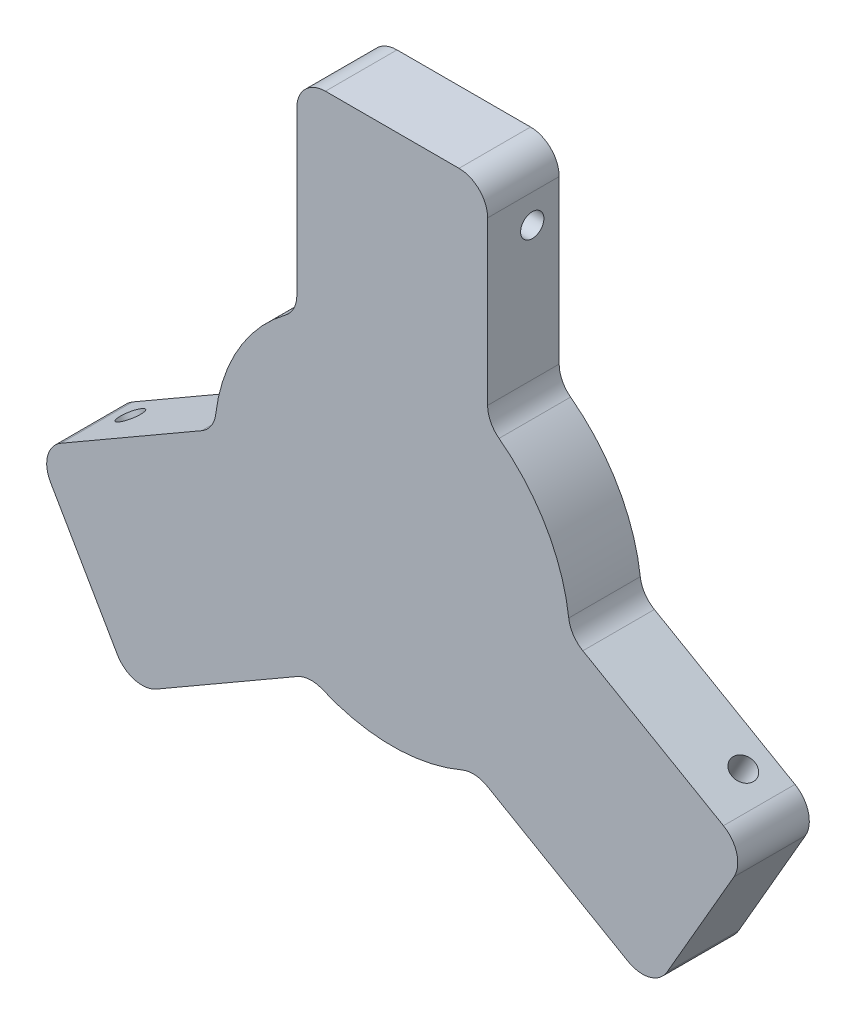
from build123d import *

# Parameters (mm, degrees)
BOSS_EXTRUDE1_DEPTH = 9.525
SKETCH3_R           = 1.55
CUT_EXTRUDE2_DEPTH  = 5.08
CUT_EXTRUDE3_START  = -5.08
SKETCH4_R           = 1.55
CUT_EXTRUDE3_DEPTH  = 5.08
CIRPATTERN2_COUNT   = 3


with BuildPart() as part:
    # Sketch1 → Boss-Extrude1 (new body)
    with BuildSketch(Plane.XY):
        with BuildLine():
            Line((12.7, 21.969079793), (12.7, 43.5864))
            ThreePointArc((12.7, 43.5864), (11.584076836, 46.280476836), (8.89, 47.3964))
            Line((8.89, 47.3964), (-8.89, 47.3964))
            ThreePointArc((-8.89, 47.3964), (-11.584076836, 46.280476836), (-12.7, 43.5864))
            Line((-12.7, 43.5864), (-12.7, 21.969079793))
            ThreePointArc((-12.7, 21.969079793), (-13.101409662, 20.266842468), (-14.221056121, 18.923289925))
            ThreePointArc((-14.221056121, 18.923289925), (-20.499926929, 11.835638331), (-23.498577859, 2.854150907))
            ThreePointArc((-23.498577859, 2.854150907), (-24.102305263, 1.212732359), (-25.375781199, 0.013982731))
            Line((-25.375781199, 0.013982731), (-44.09692966, -10.794677372))
            ThreePointArc((-44.09692966, -10.794677372), (-45.872107058, -13.108133599), (-45.491486448, -15.99923416))
            Line((-45.491486448, -15.99923416), (-36.601486448, -31.39716584))
            ThreePointArc((-36.601486448, -31.39716584), (-34.288030221, -33.172343238), (-31.39692966, -32.791722628))
            Line((-31.39692966, -32.791722628), (-12.675781199, -21.983062525))
            ThreePointArc((-12.675781199, -21.983062525), (-11.000895601, -21.479574827), (-9.277521738, -21.777440832))
            ThreePointArc((-9.277521738, -21.777440832), (0, -23.671276662), (9.277521738, -21.777440832))
            ThreePointArc((9.277521738, -21.777440832), (11.000895601, -21.479574827), (12.675781199, -21.983062525))
            Line((12.675781199, -21.983062525), (31.39692966, -32.791722628))
            ThreePointArc((31.39692966, -32.791722628), (34.288030221, -33.172343238), (36.601486448, -31.39716584))
            Line((36.601486448, -31.39716584), (45.491486448, -15.99923416))
            ThreePointArc((45.491486448, -15.99923416), (45.872107058, -13.108133599), (44.09692966, -10.794677372))
            Line((44.09692966, -10.794677372), (25.375781199, 0.013982731))
            ThreePointArc((25.375781199, 0.013982731), (24.102305263, 1.212732359), (23.498577859, 2.854150907))
            ThreePointArc((23.498577859, 2.854150907), (20.499926929, 11.835638331), (14.221056121, 18.923289925))
            ThreePointArc((14.221056121, 18.923289925), (13.101409662, 20.266842468), (12.7, 21.969079793))
        make_face()
    extrude(amount=BOSS_EXTRUDE1_DEPTH)

    # Sketch3 → Cut-Extrude2 (cut)
    with BuildSketch(Plane(origin=(-6.35, -10.998522628, 0), x_dir=(0.8660254037844575, -0.4999999999999674, 0), z_dir=(-0.4999999999999675, -0.8660254037844576, 0))):
        with Locations((39.7764, 3.582)):
            Circle(SKETCH3_R)
    cut_extrude2 = extrude(amount=-CUT_EXTRUDE2_DEPTH, mode=Mode.SUBTRACT)

    # Sketch4 → Cut-Extrude3 (cut)
    with BuildSketch(Plane(origin=(6.35, 10.998522628, 0), x_dir=(0.8660254037844387, -0.49999999999999983, 0), z_dir=(0.49999999999999983, 0.8660254037844387, 0)).offset(CUT_EXTRUDE3_START)):
        with Locations((39.7764, -3.582)):
            Circle(SKETCH4_R)
    cut_extrude3 = extrude(amount=CUT_EXTRUDE3_DEPTH, mode=Mode.SUBTRACT)

    # CirPattern2: Cut-Extrude2, Cut-Extrude3 ×3 about axis
    cirpattern2_axis = Axis((0, 0, 0), (0, 0, -1))
    add([cut_extrude2.rotate(cirpattern2_axis, i * 360 / CIRPATTERN2_COUNT) for i in range(1, CIRPATTERN2_COUNT)], mode=Mode.SUBTRACT)
    add([cut_extrude3.rotate(cirpattern2_axis, i * 360 / CIRPATTERN2_COUNT) for i in range(1, CIRPATTERN2_COUNT)], mode=Mode.SUBTRACT)


solid = part.part
